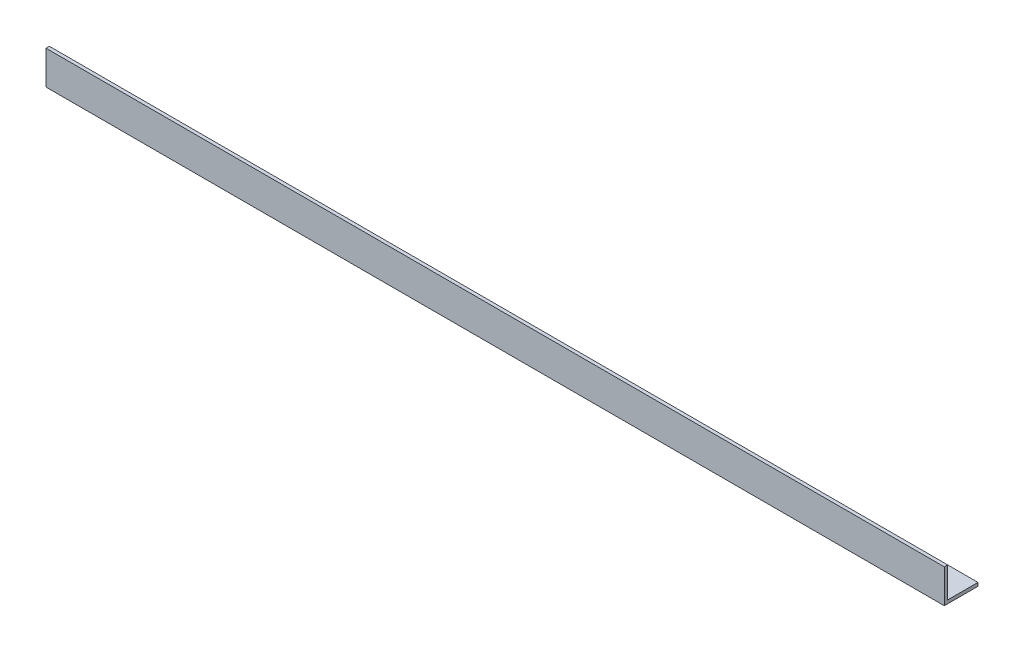
from build123d import *

# Parameters (mm, degrees)
EXTRUDE_1_DEPTH = 400


with BuildPart() as part:
    # Эскиз1 → Бобышка-Вытянуть1 (new body)
    with BuildSketch(Plane(origin=(0, 0, 0), x_dir=(0, 0, -1), z_dir=(1, 0, 0))):
        Polygon((0, 0), (0, 15), (1.5, 15), (1.5, 1.5), (15, 1.5), (15, 0), align=None)
    extrude(amount=EXTRUDE_1_DEPTH)


solid = part.part
